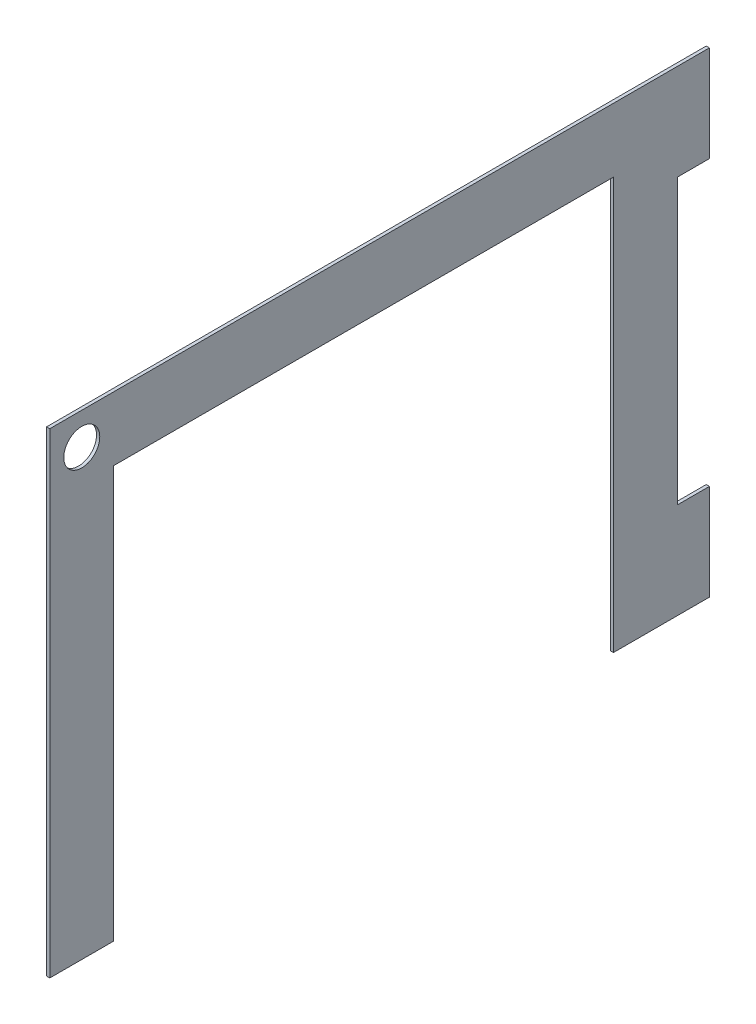
from build123d import *

# Parameters (mm, degrees)
SKETCH1_R           = 14.2875
BOSS_EXTRUDE1_DEPTH = 1.27


with BuildPart() as part:
    # Sketch1 → Boss-Extrude1 (new body, symmetric)
    with BuildSketch(Plane(origin=(0, 0, 0), x_dir=(0, 0, -1), z_dir=(1, 0, 0))):
        Polygon((-201.134911254, -254), (-201.134911254, 123.825), (297.346438746, 123.825), (322.746438746, 123.825), (322.746438746, 47.625), (297.346438746, 47.625), (297.346438746, -177.8), (322.746438746, -177.8), (322.746438746, -254), (297.346438746, -254), (246.546438746, -254), (246.546438746, 73.025), (-150.334911254, 73.025), (-150.334911254, -254), align=None)
        with Locations((-175.734911254, 98.425)):
            Circle(SKETCH1_R, mode=Mode.SUBTRACT)
    extrude(amount=BOSS_EXTRUDE1_DEPTH, both=True)


solid = part.part
